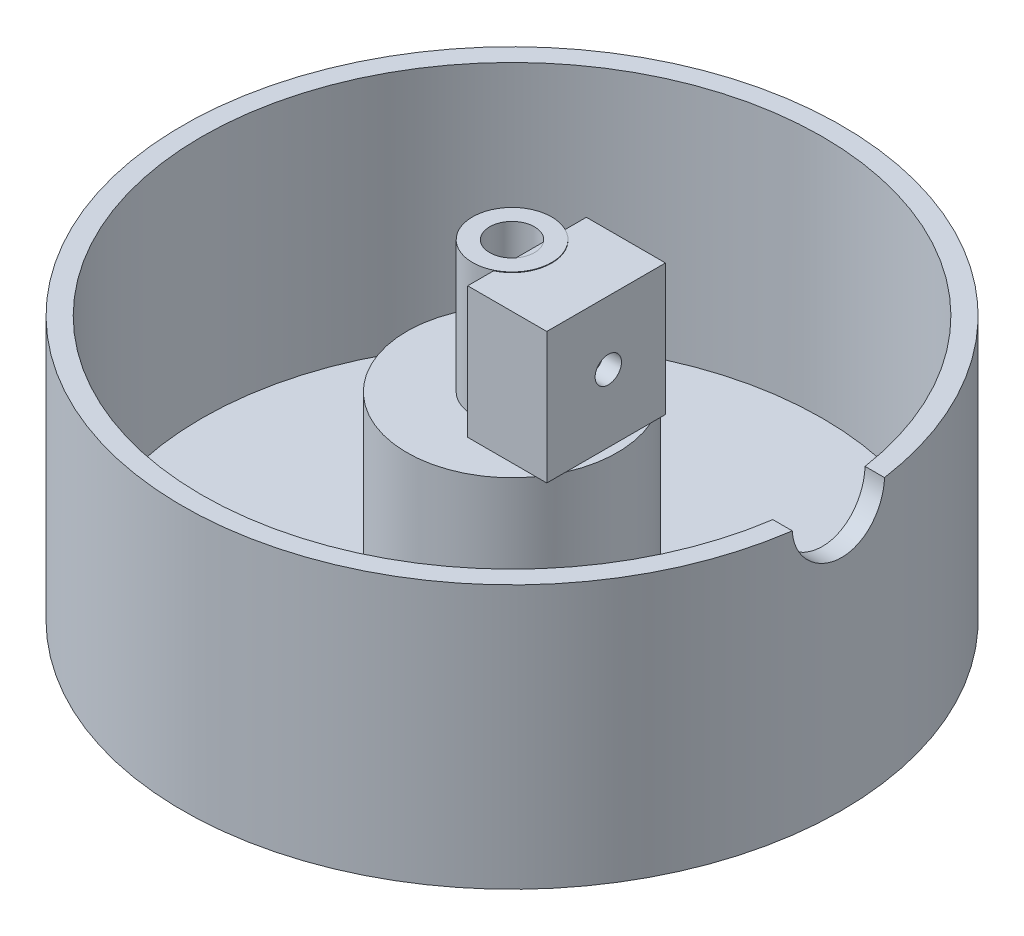
from build123d import *

# Parameters (mm, degrees)
SKETCH1_R               = 6
BOSS_EXTRUDE1_DEPTH     = 20
SKETCH2_R               = 3.4
CUT_EXTRUDE1_DEPTH      = 13.55
SKETCH5_W               = 1.550685087
SKETCH5_H               = 7.184215806
BOSS_EXTRUDE2_DEPTH     = 13.55
SKETCH7_W               = 18.003976239
SKETCH7_H               = 19.909960041
BOSS_EXTRUDE3_DEPTH     = 12
SKETCH6_R               = 2
CUT_EXTRUDE2_DEPTH      = 1
CUT_EXTRUDE2_DEPTH_BACK = 13.55
NUTOPENING_DEPTH        = 10
SKETCH10_R              = 50
BOSS_EXTRUDE4_DEPTH     = 30
SKETCH12_R              = 47.082764373
SKETCH12_R_2            = 15.95790089
CUT_EXTRUDE5_DEPTH      = 27
SKETCH13_R              = 50
SKETCH13_R_2            = 47.082764373
BOSS_EXTRUDE5_DEPTH     = 10
CUT_EXTRUDE6_DEPTH      = 6.933086
SKETCH16_R              = 7
CUT_EXTRUDE7_DEPTH      = 40


with BuildPart() as part:
    # Sketch1 → Boss-Extrude1 (new body)
    with BuildSketch(Plane(origin=(0, 0, 0), x_dir=(1, 0, 0), z_dir=(0, 1, 0))):
        Circle(SKETCH1_R)
    extrude(amount=BOSS_EXTRUDE1_DEPTH)

    # Sketch2 → Cut-Extrude1 (cut)
    with BuildSketch(Plane(origin=(0, 20, 0), x_dir=(1, 0, 0), z_dir=(0, 1, 0))):
        Circle(SKETCH2_R)
    extrude(amount=-CUT_EXTRUDE1_DEPTH, mode=Mode.SUBTRACT)

    # Sketch5 → Boss-Extrude2 (add)
    with BuildSketch(Plane(origin=(0, 18.26, 0), x_dir=(1, 0, 0), z_dir=(0, 1, 0))):
        with Locations((3.375342544, 0.020519704)):
            Rectangle(SKETCH5_W, SKETCH5_H)
    extrude(amount=-BOSS_EXTRUDE2_DEPTH)

    # Sketch7 → Boss-Extrude3 (add)
    with BuildSketch(Plane.ZY.offset(-2.6)):
        with Locations((0.33027221, 9.954980021)):
            Rectangle(SKETCH7_W, SKETCH7_H)
    extrude(amount=-BOSS_EXTRUDE3_DEPTH)

    # Sketch6 → Cut-Extrude2 (cut, two sides)
    with BuildSketch(Plane.ZY.offset(-2.6)) as cut_extrude2_sk:
        with Locations((0, 10.236925537)):
            Circle(SKETCH6_R)
    extrude(amount=CUT_EXTRUDE2_DEPTH, mode=Mode.SUBTRACT)
    extrude(cut_extrude2_sk.sketch, amount=-CUT_EXTRUDE2_DEPTH_BACK, mode=Mode.SUBTRACT)

    # Sketch9 → NutOpening (cut)
    with BuildSketch(Plane.XY):
        Polygon((11.876516377, 10.236925537), (11.876516377, 5.861925537), (4.943430227, 5.861925537), (4.943430227, 10.236925537), (4.943430227, 14.614332445), (11.876516377, 14.614332445), align=None)
    extrude(amount=-NUTOPENING_DEPTH, mode=Mode.SUBTRACT)

    # Sketch10 → Boss-Extrude4 (add)
    with BuildSketch(Plane.XZ):
        Circle(SKETCH10_R)
    extrude(amount=BOSS_EXTRUDE4_DEPTH)

    # Sketch12 → Cut-Extrude5 (cut)
    with BuildSketch(Plane(origin=(0, 0, 0), x_dir=(1, 0, 0), z_dir=(0, 1, 0))):
        Circle(SKETCH12_R)
        Circle(SKETCH12_R_2, mode=Mode.SUBTRACT)
    extrude(amount=-CUT_EXTRUDE5_DEPTH, mode=Mode.SUBTRACT)

    # Sketch13 → Boss-Extrude5 (add)
    with BuildSketch(Plane(origin=(0, 0, 0), x_dir=(1, 0, 0), z_dir=(0, 1, 0))):
        Circle(SKETCH13_R)
        Circle(SKETCH13_R_2, mode=Mode.SUBTRACT)
    extrude(amount=BOSS_EXTRUDE5_DEPTH)

    # Sketch14 → Cut-Extrude6 (cut)
    with BuildSketch(Plane.ZY.offset(-11.876516377)):
        Polygon((-5.054124256, 10.236925537), (-2.527062128, 5.859925537), (2.527062128, 5.859925537), (5.054124256, 10.236925537), (2.527062128, 14.613925537), (-2.527062128, 14.613925537), align=None)
    extrude(amount=CUT_EXTRUDE6_DEPTH, mode=Mode.SUBTRACT)

    # Sketch16 → Cut-Extrude7 (cut)
    with BuildSketch(Plane(origin=(14.6, 0, 0), x_dir=(0, 0, -1), z_dir=(1, 0, 0))):
        with Locations((0, 10.236925537)):
            Circle(SKETCH16_R)
    extrude(amount=CUT_EXTRUDE7_DEPTH, mode=Mode.SUBTRACT)


solid = part.part
